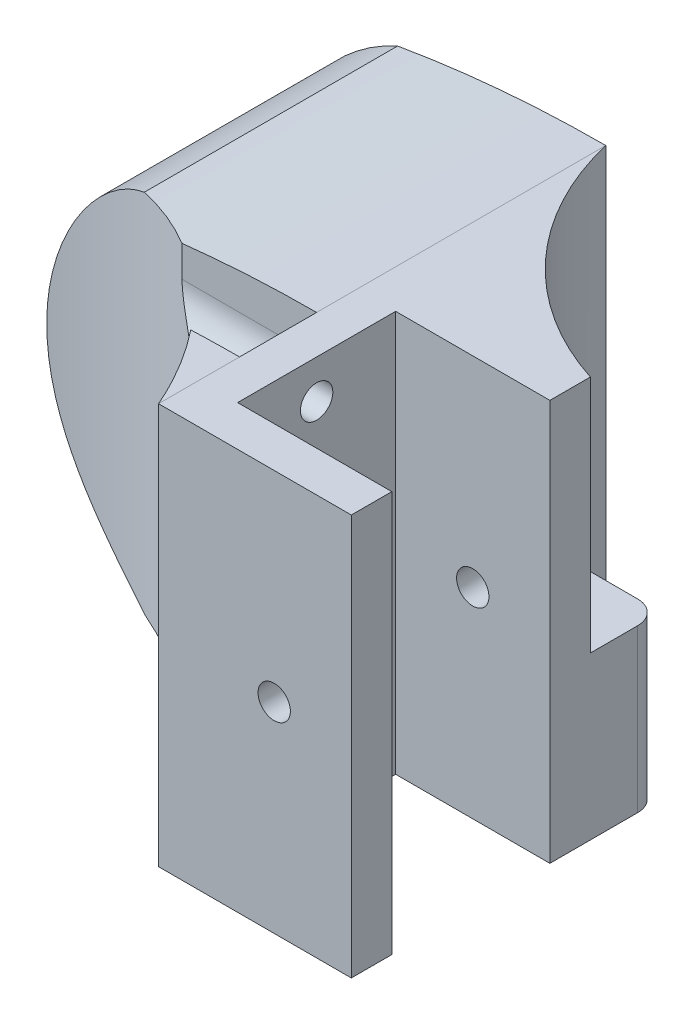
from build123d import *

# Parameters (mm, degrees)
SKETCH_1_W              = 52
SKETCH_1_H              = 52
EXTRUDE_1_DEPTH         = 31
SKETCH_2_W              = 20.5
SKETCH_2_H              = 52
CUT_EXTRUDE_1_DEPTH     = 20
SKETCH_5_R              = 26
EXTRUDE_2_DEPTH         = 31
CUT_EXTRUDE_2_DEPTH     = 32
SKETCH_7_W              = 20
SKETCH_7_H              = 20.5
CUT_EXTRUDE_3_DEPTH     = 53
EXTRUDE_3_DEPTH         = 27
SKETCH_10_W             = 19
SKETCH_10_H             = 14
SKETCH_11_W             = 19
SKETCH_11_H             = 28
CUT_EXTRUDE_4_DEPTH     = 27
EXTRUDE_4_DEPTH         = 52
SKETCH_13_R             = 2.1
CUT_EXTRUDE_5_DEPTH     = 59
SKETCH_14_R             = 2.1
CUT_EXTRUDE_6_DEPTH     = 48.25
SKETCH_15_R             = 5
CUT_EXTRUDE_7_DEPTH     = 43.2500001
SKETCH_17_W             = 10
SKETCH_17_H             = 42.25
CUT_EXTRUDE_8_DEPTH     = 6.0000001
SKETCH_18_R             = 5
CUT_EXTRUDE_9_DEPTH     = 28.0000001
SKETCH_19_R             = 2.5
CUT_EXTRUDE_10_DEPTH    = 59.0000001
CUT_EXTRUDE1_DEPTH      = 53.0000001
SKETCH3_R               = 7.5
CUT_EXTRUDE2_DEPTH      = 22.300523217
CUT_EXTRUDE2_DEPTH_BACK = 2
CUT_EXTRUDE_12_DEPTH    = 28.0000001
SKETCH_20_W             = 20
SKETCH_20_H             = 14.39
EXTRUDE_5_DEPTH         = 21
CUT_EXTRUDE_11_DEPTH    = 15
FILLET_1_R              = 3


with BuildPart() as part:
    # Эскиз1 → Бобышка-Вытянуть1 (new body)
    with BuildSketch(Plane.XY):
        with Locations((26, 0)):
            Rectangle(SKETCH_1_W, SKETCH_1_H)
    extrude(amount=EXTRUDE_1_DEPTH)

    # Эскиз2 → Вырез-Вытянуть1 (cut)
    with BuildSketch(Plane.ZY):
        with Locations((15.5, 0)):
            Rectangle(SKETCH_2_W, SKETCH_2_H)
    extrude(amount=-CUT_EXTRUDE_1_DEPTH, mode=Mode.SUBTRACT)

    # Эскиз5 → Бобышка-Вытянуть2 (add)
    with BuildSketch(Plane.XY.offset(31)):
        with Locations((41.25, 0)):
            Circle(SKETCH_5_R)
    extrude(amount=-EXTRUDE_2_DEPTH)

    # Эскиз6 → Вырез-Вытянуть2 (cut, through all)
    with BuildSketch(Plane.XY.offset(31)):
        with BuildLine():
            Line((52, 23.673561202), (52, 26))
            Line((52, 26), (25, 26))
            ThreePointArc((25, 26), (38.550021379, 25.417314778), (52, 23.673561202))
        make_face()
    cut_extrude_2 = extrude(amount=-CUT_EXTRUDE_2_DEPTH, mode=Mode.SUBTRACT)

    # Зеркальное отражение1: Вырез-Вытянуть2 across plane
    add(cut_extrude_2.mirror(Plane(origin=(0, 0, 0), x_dir=(0, 0, 1), z_dir=(0, -1, 0))), mode=Mode.SUBTRACT)

    # Эскиз7 → Вырез-Вытянуть3 (cut, through all)
    with BuildSketch(Plane(origin=(0, 26, 0), x_dir=(1, 0, 0), z_dir=(0, 1, 0))):
        with Locations((10, -15.5)):
            Rectangle(SKETCH_7_W, SKETCH_7_H)
    extrude(amount=-CUT_EXTRUDE_3_DEPTH, mode=Mode.SUBTRACT)

    # Эскиз9 → Бобышка-Вытянуть3 (add)
    with BuildSketch(Plane(origin=(0, 0, 0), x_dir=(-1, 0, 0), z_dir=(0, 0, -1))):
        with BuildLine():
            Line((-25, 26), (-25, -26))
            ThreePointArc((-25, -26), (-38.550021379, -25.417314778), (-52, -23.673561202))
            ThreePointArc((-52, -23.673561202), (-67.25, 0), (-52, 23.673561202))
            ThreePointArc((-52, 23.673561202), (-38.550021379, 25.417314778), (-25, 26))
        make_face()
    extrude(amount=EXTRUDE_3_DEPTH)

    # Эскиз10 → Вырез-Повернуть2 (revolve, cut)
    with BuildSketch(Plane.ZY.offset(-41.25)):
        with Locations((-11.25, 7)):
            Rectangle(SKETCH_10_W, SKETCH_10_H)
    revolve(axis=Axis((41.25, 0, -20.75), (0, 0, 1)), mode=Mode.SUBTRACT)

    # Эскиз11 → Вырез-Вытянуть4 (cut, through all)
    with BuildSketch(Plane(origin=(0, 0, 0), x_dir=(0, 0, -1), z_dir=(0, -1, 0))):
        with Locations((11.25, 41.25)):
            Rectangle(SKETCH_11_W, SKETCH_11_H)
    extrude(amount=CUT_EXTRUDE_4_DEPTH, mode=Mode.SUBTRACT)

    # Эскиз12 → Бобышка-Вытянуть4 (add)
    with BuildSketch(Plane.XZ.offset(26)):
        with BuildLine():
            Line((0, 0), (25, 0))
            Line((25, 0), (25, -27))
            ThreePointArc((25, -27), (16.039335617, -10.222837391), (0, 0))
        make_face()
    extrude(amount=-EXTRUDE_4_DEPTH)

    # Эскиз13 → Вырез-Вытянуть5 (cut, through all)
    with BuildSketch(Plane.XY.offset(31)):
        with Locations((10, 0)):
            Circle(SKETCH_13_R)
    extrude(amount=-CUT_EXTRUDE_5_DEPTH, mode=Mode.SUBTRACT)

    # Эскиз14 → Вырез-Вытянуть6 (cut, through all)
    with BuildSketch(Plane.ZY.offset(-20)):
        with Locations((15.5, -21)):
            Circle(SKETCH_14_R)
        with Locations((15.5, 21)):
            Circle(SKETCH_14_R)
    extrude(amount=-CUT_EXTRUDE_6_DEPTH, mode=Mode.SUBTRACT)

    # Эскиз15 → Вырез-Вытянуть7 (cut, through all)
    with BuildSketch(Plane(origin=(25, 0, 0), x_dir=(0, 0, -1), z_dir=(1, 0, 0))):
        with Locations((-15.5, 21)):
            Circle(SKETCH_15_R)
        with Locations((-15.5, -21)):
            Circle(SKETCH_15_R)
    extrude(amount=CUT_EXTRUDE_7_DEPTH, mode=Mode.SUBTRACT)

    # Эскиз17 → Вырез-Вытянуть8 (cut, through all)
    with BuildSketch(Plane(origin=(0, 21, 0), x_dir=(0, 0, -1), z_dir=(0, 1, 0))):
        with Locations((-15.5, -46.125)):
            Rectangle(SKETCH_17_W, SKETCH_17_H)
    cut_extrude_8 = extrude(amount=CUT_EXTRUDE_8_DEPTH, mode=Mode.SUBTRACT)

    # Зеркальное отражение2: Вырез-Вытянуть8 across plane
    add(cut_extrude_8.mirror(Plane(origin=(0, 0, 0), x_dir=(0, 0, 1), z_dir=(0, -1, 0))), mode=Mode.SUBTRACT)

    # Эскиз18 → Вырез-Вытянуть9 (cut, through all)
    with BuildSketch(Plane(origin=(0, 0, 0), x_dir=(-1, 0, 0), z_dir=(0, 0, -1))):
        with Locations((-10, 0)):
            Circle(SKETCH_18_R)
    extrude(amount=CUT_EXTRUDE_9_DEPTH, mode=Mode.SUBTRACT)

    # Эскиз19 → Вырез-Вытянуть10 (cut, through all)
    with BuildSketch(Plane.XY.offset(31)):
        with Locations((41.25, 0)):
            Circle(SKETCH_19_R)
    extrude(amount=-CUT_EXTRUDE_10_DEPTH, mode=Mode.SUBTRACT)


with BuildPart() as body_2:
    # Зеркальное отражение3: mirrored copy
    add(part.part.mirror(Plane.ZY))

    # Sketch1 → Cut-Extrude1 (cut, through all)
    with BuildSketch(Plane(origin=(0, 26, 0), x_dir=(1, 0, 0), z_dir=(0, 1, 0))):
        with BuildLine():
            Line((-67.25, -31), (-25, -31))
            ThreePointArc((-25, -31), (-41.975877859, -10.807868092), (-67.25, -3.25))
            Line((-67.25, -3.25), (-67.25, -31))
        make_face()
    extrude(amount=-CUT_EXTRUDE1_DEPTH, mode=Mode.SUBTRACT)

    # Sketch3 → Cut-Extrude2 (cut, two sides)
    with BuildSketch(Plane.XY.offset(9.699476883)) as cut_extrude2_sk:
        with Locations((-41.25, 0)):
            Circle(SKETCH3_R)
    extrude(amount=CUT_EXTRUDE2_DEPTH, mode=Mode.SUBTRACT)
    extrude(cut_extrude2_sk.sketch, amount=-CUT_EXTRUDE2_DEPTH_BACK, mode=Mode.SUBTRACT)

    # Эскиз23 → Вырез-Вытянуть12 (cut, through all)
    with BuildSketch(Plane(origin=(0, 0, 0), x_dir=(-1, 0, 0), z_dir=(0, 0, -1))):
        with BuildLine():
            Line((10, 5), (0, 5))
            Line((0, 5), (0, -5))
            Line((0, -5), (10, -5))
            Line((10, -5), (15, -5))
            Line((15, -5), (15, 0))
            ThreePointArc((15, 0), (13.535533906, 3.535533906), (10, 5))
        make_face()
    extrude(amount=CUT_EXTRUDE_12_DEPTH, mode=Mode.SUBTRACT)

    # Эскиз20 → Бобышка-Вытянуть5 (add)
    with BuildSketch(Plane.XZ.offset(26)):
        with Locations((-10, -1.945)):
            Rectangle(SKETCH_20_W, SKETCH_20_H)
    extrude(amount=-EXTRUDE_5_DEPTH)

    # Эскиз22 → Вырез-Вытянуть11 (cut)
    with BuildSketch(Plane.XZ.offset(26)):
        Polygon((-10, 1.925426481), (-12.75, 0.33771324), (-12.75, -2.83771324), (-10, -4.425426481), (-7.25, -2.83771324), (-7.25, 0.33771324), align=None)
    extrude(amount=-CUT_EXTRUDE_11_DEPTH, mode=Mode.SUBTRACT)

    # Скругление1
    fillet_1_edges = [body_2.edges().sort_by_distance(p)[0] for p in [
        (0, -15.5, -9.14),
    ]]
    fillet(fillet_1_edges, radius=FILLET_1_R)


solid = body_2.part
